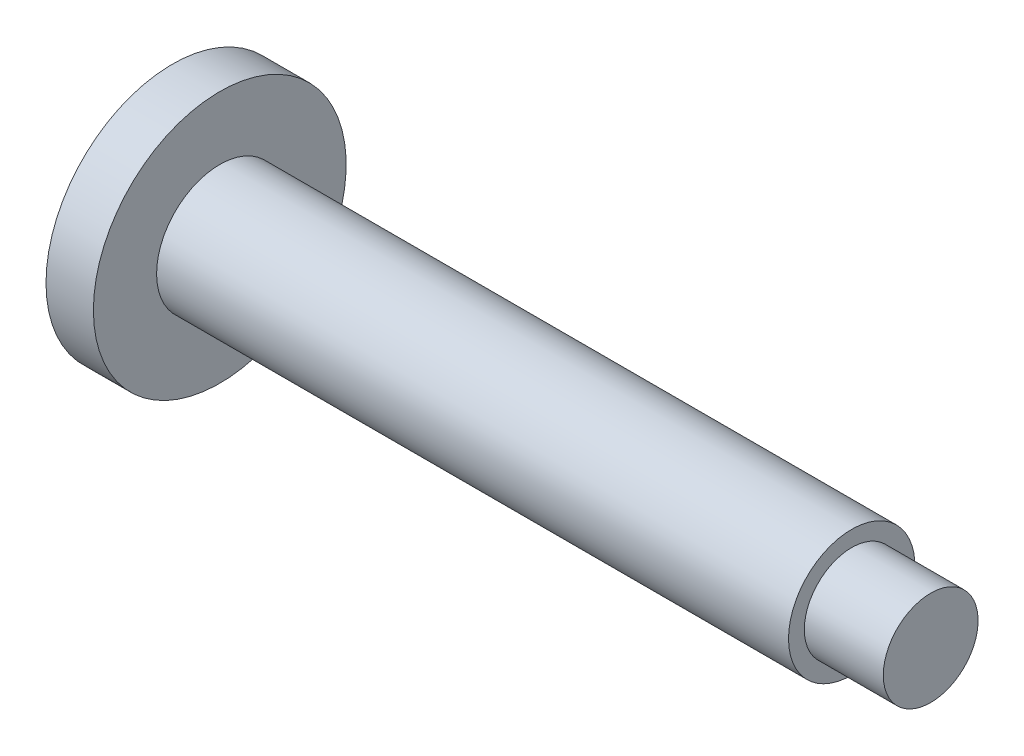
from build123d import *


with BuildPart() as part:
    # Sketch1 → Revolve1 (revolve)
    with BuildSketch(Plane.XY):
        Polygon((0, 0), (0, 8), (3, 8), (3, 4), (43, 4), (43, 3), (48, 3), (48, 0), align=None)
    revolve(axis=Axis((0, 0, 0), (1, 0, 0)))


solid = part.part
